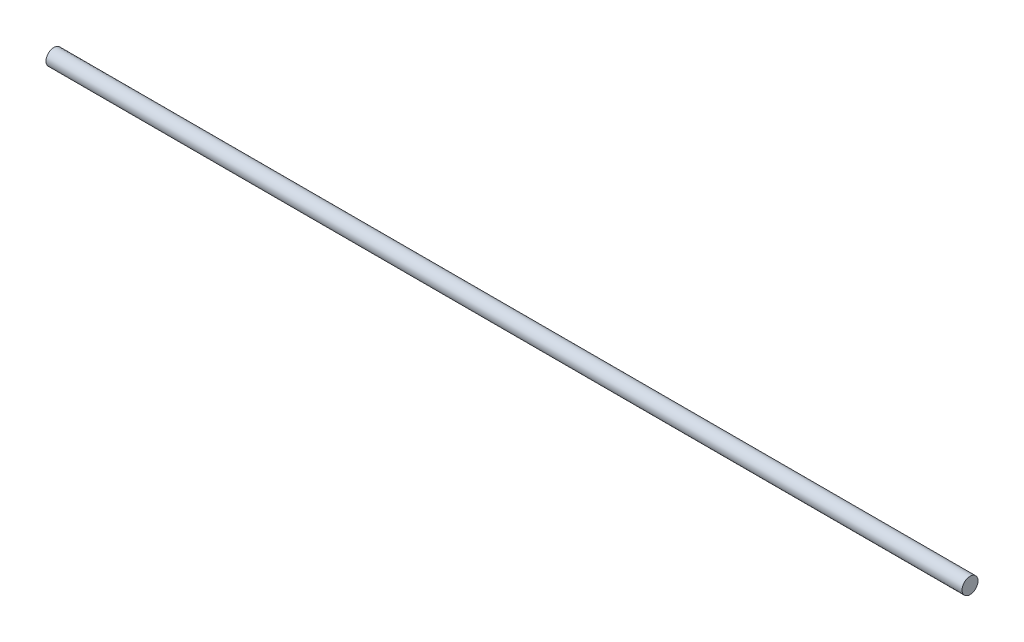
from build123d import *

# Parameters (mm, degrees)
SKETCH1_R           = 4
BOSS_EXTRUDE1_DEPTH = 460


with BuildPart() as part:
    # Sketch1 → Boss-Extrude1 (new body)
    with BuildSketch(Plane(origin=(0, 0, 0), x_dir=(0, 0, -1), z_dir=(1, 0, 0))):
        Circle(SKETCH1_R)
    extrude(amount=BOSS_EXTRUDE1_DEPTH)


solid = part.part
